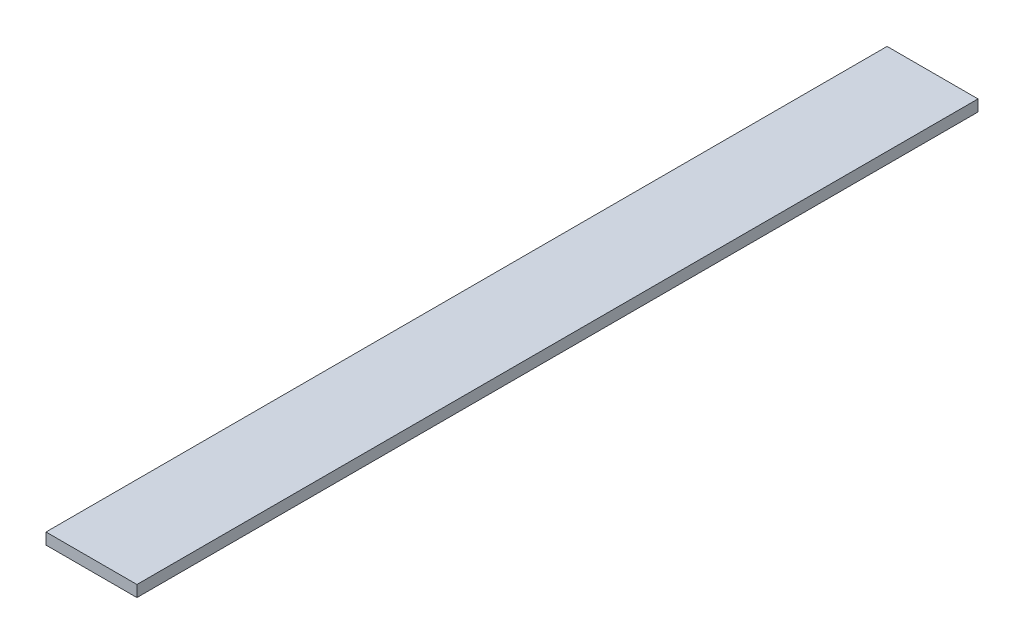
from build123d import *

# Parameters (mm, degrees)
SKETCH1_W           = 25.4
SKETCH1_H           = 234.95
BOSS_EXTRUDE1_DEPTH = 3.175


with BuildPart() as part:
    # Sketch1 → Boss-Extrude1 (new body)
    with BuildSketch(Plane(origin=(0, 0, 0), x_dir=(1, 0, 0), z_dir=(0, 1, 0))):
        Rectangle(SKETCH1_W, SKETCH1_H)
    extrude(amount=BOSS_EXTRUDE1_DEPTH)


solid = part.part
